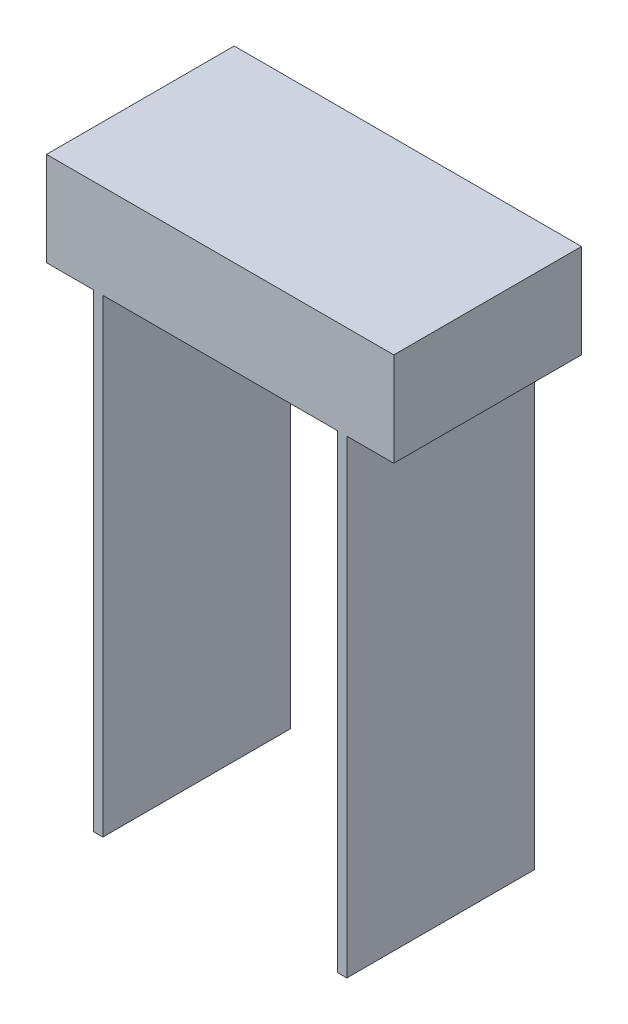
from build123d import *

# Parameters (mm, degrees)
BOSS_EXTRUDE1_DEPTH = 8


with BuildPart() as part:
    # Sketch1 → Boss-Extrude1 (new body)
    with BuildSketch(Plane.XY):
        Polygon((-10.623376623, -7.87012987), (-10.223376623, -7.87012987), (-10.223376623, 12.12987013), (-0.223376623, 12.12987013), (-0.223376623, -7.87012987), (0.176623377, -7.87012987), (0.176623377, 12.12987013), (2.176623377, 12.12987013), (2.176623377, 16.12987013), (-12.623376623, 16.12987013), (-12.623376623, 12.12987013), (-10.623376623, 12.12987013), align=None)
    extrude(amount=BOSS_EXTRUDE1_DEPTH)


solid = part.part
